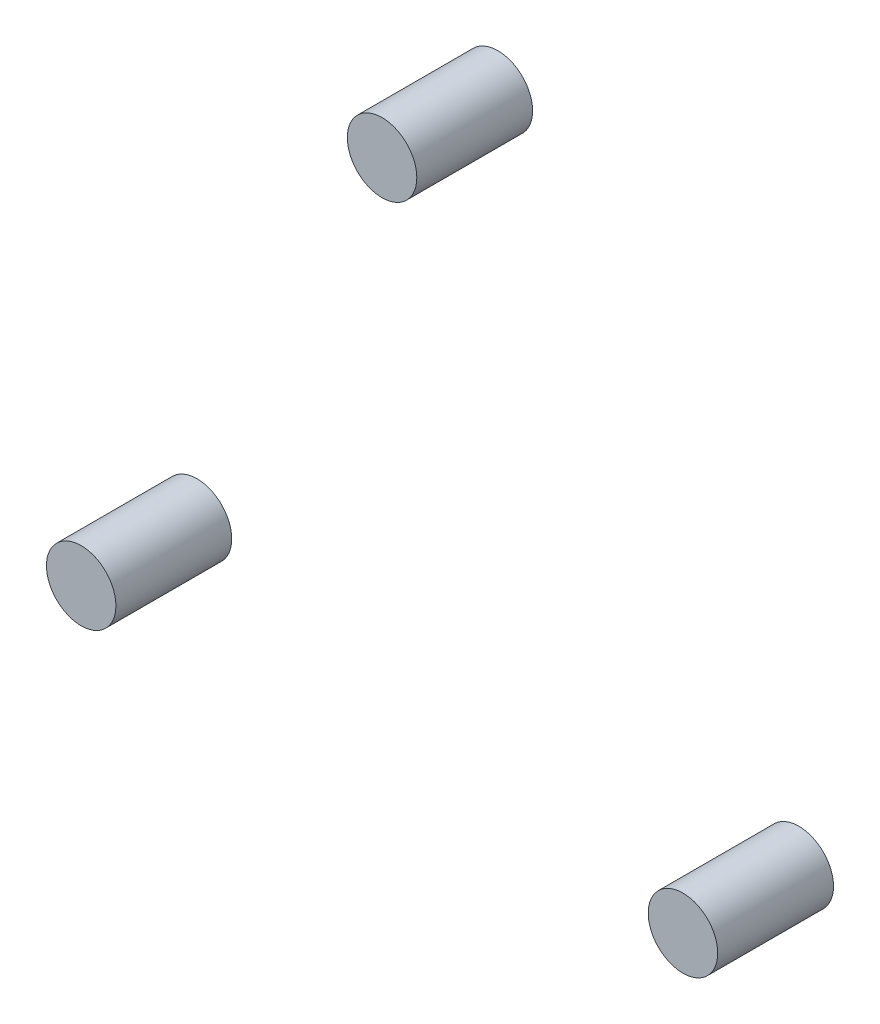
from build123d import *

# Parameters (mm, degrees)
SKIZZE1_R                         = 1.5
AUFSATZ_LINEAR_AUSTRAGEN1_DEPTH   = 5
AUFSATZ_LINEAR_AUSTRAGEN1_2_DEPTH = 5
AUFSATZ_LINEAR_AUSTRAGEN1_3_DEPTH = 5


with BuildPart() as part:
    # Skizze1 → Aufsatz-Linear austragen1 (new body)
    with BuildSketch(Plane.XY):
        with Locations((0, 15)):
            Circle(SKIZZE1_R)
    extrude(amount=-AUFSATZ_LINEAR_AUSTRAGEN1_DEPTH)


with BuildPart() as body_2:
    # Skizze1 → Aufsatz-Linear austragen1 2 (new body)
    with BuildSketch(Plane.XY):
        with Locations((12.990381057, -7.5)):
            Circle(SKIZZE1_R)
    extrude(amount=-AUFSATZ_LINEAR_AUSTRAGEN1_2_DEPTH)


with BuildPart() as body_3:
    # Skizze1 → Aufsatz-Linear austragen1 3 (new body)
    with BuildSketch(Plane.XY):
        with Locations((-12.990381057, -7.5)):
            Circle(SKIZZE1_R)
    extrude(amount=-AUFSATZ_LINEAR_AUSTRAGEN1_3_DEPTH)


solid = Compound([part.part, body_2.part, body_3.part])
